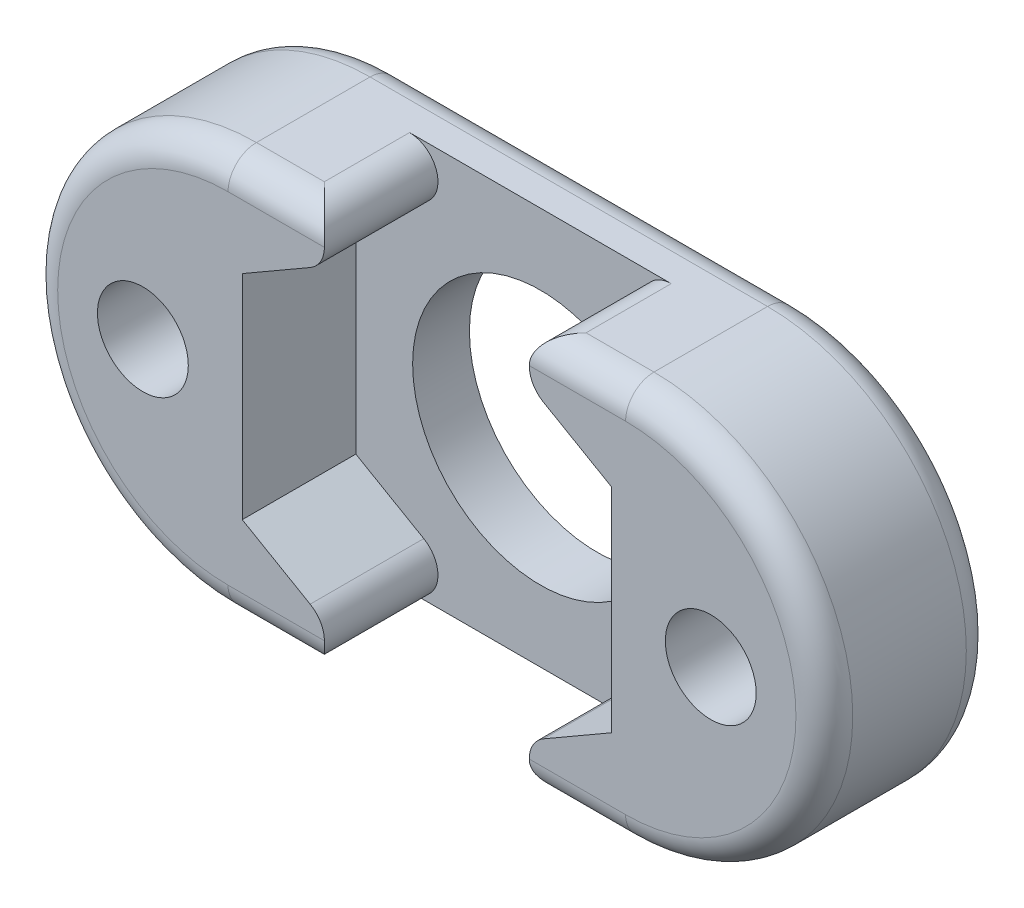
from build123d import *

# Parameters (mm, degrees)
BOSS_EXTRU_1_DEPTH      = 6
ESQUISSE3_R             = 4.5
ESQUISSE3_R_2           = 1.6
ENL_V_MAT_EXTRU_1_DEPTH = 7
ENL_V_MAT_EXTRU_2_DEPTH = 4
CONG_1_R                = 1


with BuildPart() as part:
    # Esquisse1 → Boss.-Extru.1 (new body)
    with BuildSketch(Plane.XY):
        with BuildLine():
            Line((-27.254178511, 7), (-13.254178511, 7))
            ThreePointArc((-13.254178511, 7), (-6.254178511, 0), (-13.254178511, -7))
            Line((-13.254178511, -7), (-27.254178511, -7))
            ThreePointArc((-27.254178511, -7), (-34.254178511, 0), (-27.254178511, 7))
        make_face()
    extrude(amount=BOSS_EXTRU_1_DEPTH)

    # Esquisse3 → Enlèv. mat.-Extru.1 (cut, through all)
    with BuildSketch(Plane.XY.offset(6)):
        with Locations((-20.254178511, 0)):
            Circle(ESQUISSE3_R)
        with Locations((-30.254178511, 0)):
            Circle(ESQUISSE3_R_2)
        with Locations((-10.254178511, 0)):
            Circle(ESQUISSE3_R_2)
    extrude(amount=-ENL_V_MAT_EXTRU_1_DEPTH, mode=Mode.SUBTRACT)

    # Esquisse4 → Enlèv. mat.-Extru.2 (cut)
    with BuildSketch(Plane.XY.offset(6)):
        Polygon((-13.754178511, -3.75277675), (-13.754178511, 3.75277675), (-20.254178511, 7.505553499), (-26.754178511, 3.75277675), (-26.754178511, -3.75277675), (-20.254178511, -7.505553499), align=None)
    extrude(amount=-ENL_V_MAT_EXTRU_2_DEPTH, mode=Mode.SUBTRACT)

    # Congé1
    cong_1_edges = [part.edges().sort_by_distance(p)[0] for p in [
        (-6.254178511, 0, 6),
        (-16.316356337, 7, 6),
        (-16.316356337, -7, 6),
        (-24.192000685, 7, 6),
        (-19.378534164, -7, 4),
        (-21.129822858, -7, 4),
        (-21.129822858, 7, 4),
        (-19.378534164, 7, 4),
        (-34.254178511, 0, 6),
        (-20.254178511, 7, 0),
        (-6.254178511, 0, 0),
        (-20.254178511, -7, 0),
        (-34.254178511, 0, 0),
        (-24.192000685, -7, 6),
    ]]
    fillet(cong_1_edges, radius=CONG_1_R)


solid = part.part
